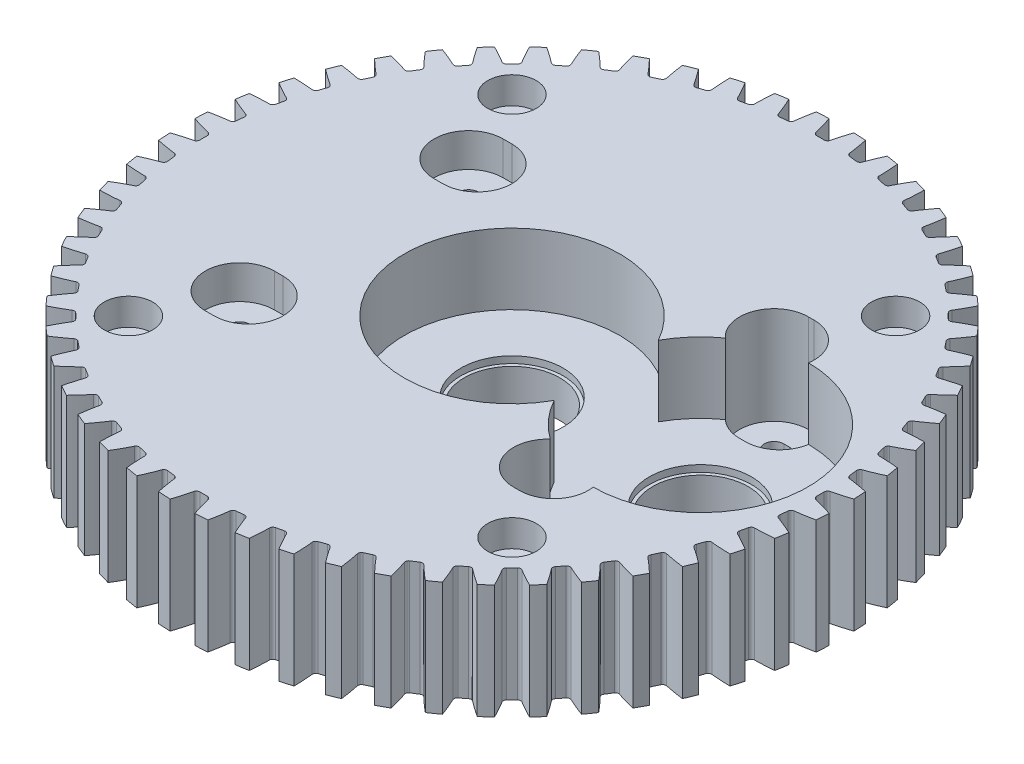
from build123d import *

# Parameters (mm, degrees)
SKETCH1_R           = 49
SKETCH1_R_2         = 2.1
BOSS_EXTRUDE1_DEPTH = 17
CUT_EXTRUDE1_DEPTH  = 72.351243857
CIRPATTERN1_COUNT   = 56
CUT_EXTRUDE2_DEPTH  = 10.5
SKETCH7_R           = 7.1
CUT_EXTRUDE3_DEPTH  = 72.303847227
SKETCH8_R           = 7.6
CUT_EXTRUDE4_DEPTH  = 11.5
CUT_EXTRUDE5_DEPTH  = 72.303847227
CUT_EXTRUDE6_DEPTH  = 14.5
SKETCH11_R          = 3.6
CUT_EXTRUDE7_DEPTH  = 4
CUT_EXTRUDE8_DEPTH  = 5


with BuildPart() as part:
    # Sketch1 → Boss-Extrude1 (new body)
    with BuildSketch(Plane(origin=(0, 0, 0), x_dir=(1, 0, 0), z_dir=(0, 1, 0))):
        Circle(SKETCH1_R)
        with Locations((-28.5, 28.5)):
            Circle(SKETCH1_R_2, mode=Mode.SUBTRACT)
        with Locations((28.5, 28.5)):
            Circle(SKETCH1_R_2, mode=Mode.SUBTRACT)
        with Locations((28.5, -28.5)):
            Circle(SKETCH1_R_2, mode=Mode.SUBTRACT)
        with Locations((-28.5, -28.5)):
            Circle(SKETCH1_R_2, mode=Mode.SUBTRACT)
    extrude(amount=BOSS_EXTRUDE1_DEPTH)

    # Sketch5 → Cut-Extrude1 (cut, through all)
    with BuildSketch(Plane(origin=(0, 17, 0), x_dir=(1, 0, 0), z_dir=(0, 1, 0))):
        with BuildLine():
            Line((-0.559830329, 45.838136275), (0.559830329, 45.838136275))
            ThreePointArc((0.559830329, 45.838136275), (0.8684537, 45.944751457), (1.045461323, 46.219129815))
            ThreePointArc((1.045461323, 46.219129815), (1.414012442, 47.600411887), (1.838663996, 48.96549106))
            ThreePointArc((1.838663996, 48.96549106), (0, 49.441035275), (-1.838663996, 48.96549106))
            ThreePointArc((-1.838663996, 48.96549106), (-1.414012442, 47.600411887), (-1.045461323, 46.219129815))
            ThreePointArc((-1.045461323, 46.219129815), (-0.8684537, 45.944751457), (-0.559830329, 45.838136275))
        make_face()
    cut_extrude1 = extrude(amount=-CUT_EXTRUDE1_DEPTH, mode=Mode.SUBTRACT)

    # CirPattern1: Cut-Extrude1 ×56 about axis
    cirpattern1_axis = Axis((0, 17, 0), (0, 1, 0))
    for i in range(1, CIRPATTERN1_COUNT):
        add(cut_extrude1.rotate(cirpattern1_axis, i * 360 / CIRPATTERN1_COUNT), mode=Mode.SUBTRACT)

    # Sketch6 → Cut-Extrude2 (cut)
    with BuildSketch(Plane(origin=(0, 17, 0), x_dir=(1, 0, 0), z_dir=(0, 1, 0))):
        with BuildLine():
            ThreePointArc((14, 7.745966692), (-16, 0), (14, -7.745966692))
            ThreePointArc((14, -7.745966692), (44, 0), (14, 7.745966692))
        make_face()
    extrude(amount=-CUT_EXTRUDE2_DEPTH, mode=Mode.SUBTRACT)

    # Sketch7 → Cut-Extrude3 (cut, through all)
    with BuildSketch(Plane(origin=(0, 17, 0), x_dir=(1, 0, 0), z_dir=(0, 1, 0))):
        with Locations((28, 0)):
            Circle(SKETCH7_R)
        Circle(SKETCH7_R)
    extrude(amount=-CUT_EXTRUDE3_DEPTH, mode=Mode.SUBTRACT)

    # Sketch8 → Cut-Extrude4 (cut)
    with BuildSketch(Plane(origin=(0, 17, 0), x_dir=(1, 0, 0), z_dir=(0, 1, 0))):
        Circle(SKETCH8_R)
        with Locations((28, 0)):
            Circle(SKETCH8_R)
    extrude(amount=-CUT_EXTRUDE4_DEPTH, mode=Mode.SUBTRACT)

    # Sketch9 → Cut-Extrude5 (cut, through all)
    with BuildSketch(Plane(origin=(0, 17, 0), x_dir=(1, 0, 0), z_dir=(0, 1, 0))):
        with BuildLine():
            ThreePointArc((22.15, -15.335), (20.7, -16.785), (22.15, -18.235))
            Line((22.15, -18.235), (23, -18.235))
            ThreePointArc((23, -18.235), (24.45, -16.785), (23, -15.335))
            Line((23, -15.335), (22.15, -15.335))
        make_face()
        with BuildLine():
            ThreePointArc((22.15, 18.235), (20.7, 16.785), (22.15, 15.335))
            Line((22.15, 15.335), (23, 15.335))
            ThreePointArc((23, 15.335), (24.45, 16.785), (23, 18.235))
            Line((23, 18.235), (22.15, 18.235))
        make_face()
        with BuildLine():
            ThreePointArc((-22.15, -18.45), (-20.7, -17), (-22.15, -15.55))
            Line((-22.15, -15.55), (-23.45, -15.55))
            ThreePointArc((-23.45, -15.55), (-24.9, -17), (-23.45, -18.45))
            Line((-23.45, -18.45), (-22.15, -18.45))
        make_face()
        with BuildLine():
            ThreePointArc((-22.15, 15.55), (-20.7, 17), (-22.15, 18.45))
            Line((-22.15, 18.45), (-23.45, 18.45))
            ThreePointArc((-23.45, 18.45), (-24.9, 17), (-23.45, 15.55))
            Line((-23.45, 15.55), (-22.15, 15.55))
        make_face()
    extrude(amount=-CUT_EXTRUDE5_DEPTH, mode=Mode.SUBTRACT)

    # Sketch10 → Cut-Extrude6 (cut)
    with BuildSketch(Plane(origin=(0, 17, 0), x_dir=(1, 0, 0), z_dir=(0, 1, 0))):
        with BuildLine():
            Line((23, -11.66), (22.15, -11.66))
            ThreePointArc((22.15, -11.66), (17.025, -16.785), (22.15, -21.91))
            Line((22.15, -21.91), (23, -21.91))
            ThreePointArc((23, -21.91), (28.125, -16.785), (23, -11.66))
        make_face()
        with BuildLine():
            Line((23, 21.91), (22.15, 21.91))
            ThreePointArc((22.15, 21.91), (17.025, 16.785), (22.15, 11.66))
            Line((22.15, 11.66), (23, 11.66))
            ThreePointArc((23, 11.66), (28.125, 16.785), (23, 21.91))
        make_face()
    extrude(amount=-CUT_EXTRUDE6_DEPTH, mode=Mode.SUBTRACT)

    # Sketch11 → Cut-Extrude7 (cut)
    with BuildSketch(Plane(origin=(0, 17, 0), x_dir=(1, 0, 0), z_dir=(0, 1, 0))):
        with Locations((-28.5, -28.5)):
            Circle(SKETCH11_R)
        with Locations((-28.5, 28.5)):
            Circle(SKETCH11_R)
        with Locations((28.5, 28.5)):
            Circle(SKETCH11_R)
        with Locations((28.5, -28.5)):
            Circle(SKETCH11_R)
    extrude(amount=-CUT_EXTRUDE7_DEPTH, mode=Mode.SUBTRACT)

    # Sketch10_3 → Cut-Extrude8 (cut)
    with BuildSketch(Plane(origin=(0, 17, 0), x_dir=(1, 0, 0), z_dir=(0, 1, 0))):
        with BuildLine():
            Line((-22.15, -11.875), (-23.45, -11.875))
            ThreePointArc((-23.45, -11.875), (-28.575, -17), (-23.45, -22.125))
            Line((-23.45, -22.125), (-22.15, -22.125))
            ThreePointArc((-22.15, -22.125), (-17.025, -17), (-22.15, -11.875))
        make_face()
        with BuildLine():
            Line((-22.15, 22.125), (-23.45, 22.125))
            ThreePointArc((-23.45, 22.125), (-28.575, 17), (-23.45, 11.875))
            Line((-23.45, 11.875), (-22.15, 11.875))
            ThreePointArc((-22.15, 11.875), (-17.025, 17), (-22.15, 22.125))
        make_face()
    extrude(amount=-CUT_EXTRUDE8_DEPTH, mode=Mode.SUBTRACT)


solid = part.part
